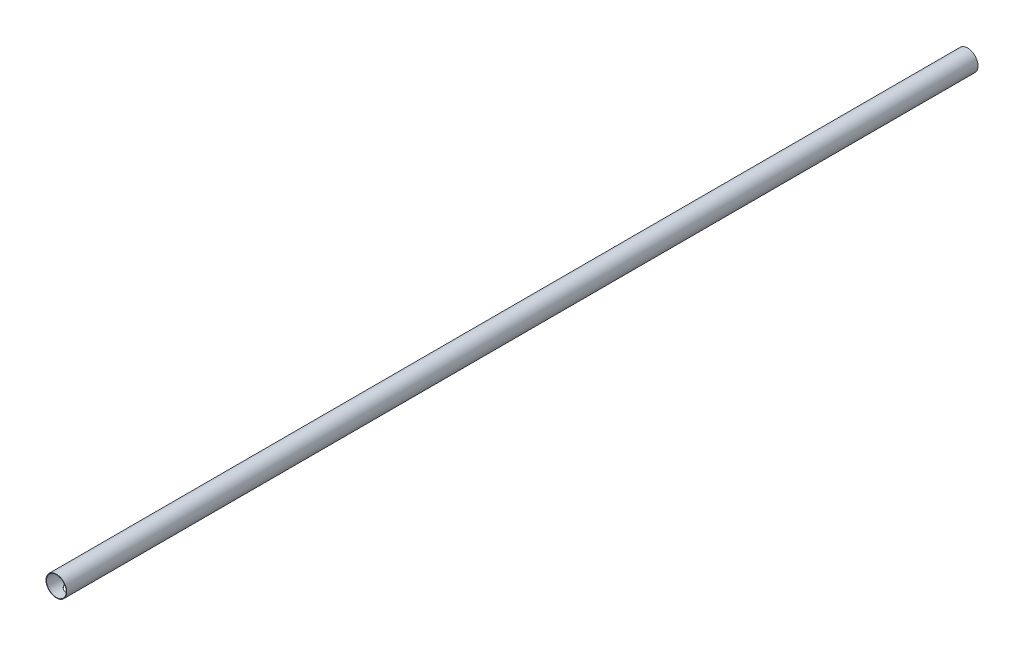
from build123d import *

# Parameters (mm, degrees)
SKETCH1_R           = 59.212106555
SKETCH1_R_2         = 56.212106555
BOSS_EXTRUDE1_DEPTH = 5200
SKETCH3_R           = 32.720251023
CUT_EXTRUDE1_DEPTH  = 100
LPATTERN1_COUNT     = 45
LPATTERN1_PITCH     = 112.42


with BuildPart() as part:
    # Sketch1 → Boss-Extrude1 (new body)
    with BuildSketch(Plane.XY):
        Circle(SKETCH1_R)
        Circle(SKETCH1_R_2, mode=Mode.SUBTRACT)
    extrude(amount=BOSS_EXTRUDE1_DEPTH)

    # Sketch3 → Cut-Extrude1 (cut)
    with BuildSketch(Plane(origin=(0, 0, 0), x_dir=(1, 0, 0), z_dir=(0, 1, 0))):
        with Locations((0, -5114.663858227)):
            Circle(SKETCH3_R)
    cut_extrude1 = extrude(amount=-CUT_EXTRUDE1_DEPTH, mode=Mode.SUBTRACT)

    # LPattern1: Cut-Extrude1 ×45
    with Locations(*[(0, 0, -i * LPATTERN1_PITCH) for i in range(1, LPATTERN1_COUNT)]):
        add(cut_extrude1, mode=Mode.SUBTRACT)


solid = part.part
